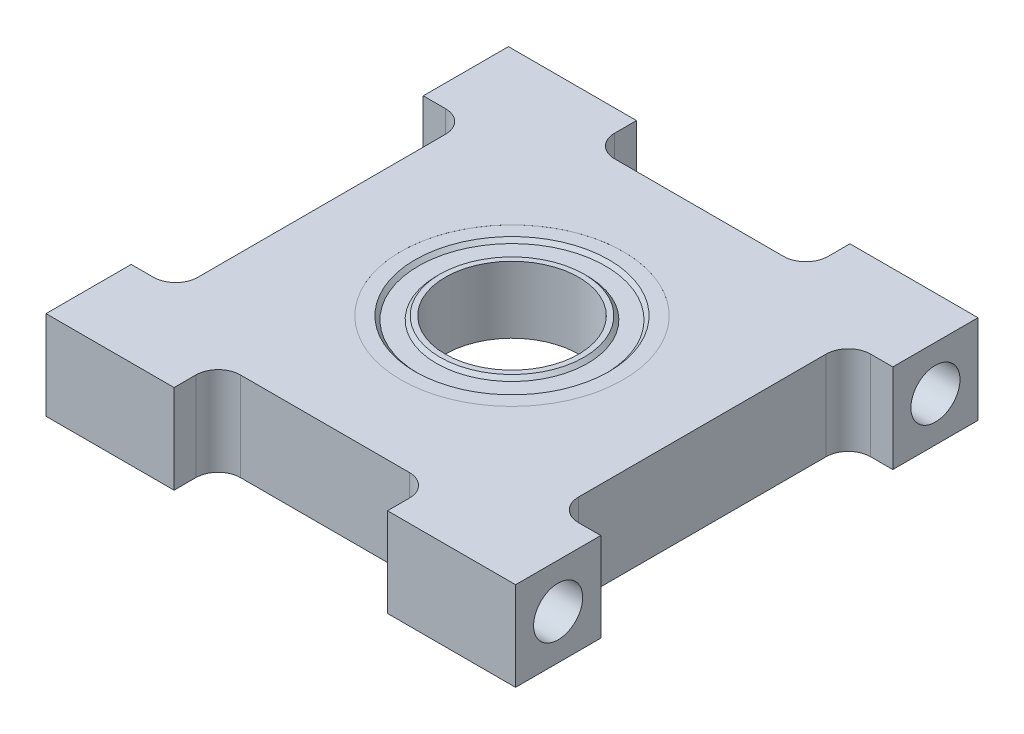
from build123d import *

# Parameters (mm, degrees)
SKETCH1_R                      = 7.62
BOSS_EXTRUDE1_DEPTH            = 6.35
SKETCH2_R                      = 7.9375
CUT_EXTRUDE1_DEPTH             = 4.7625
SKETCH3_R                      = 7.9375
SKETCH3_R_2                    = 6.6675
BOSS_EXTRUDE2_DEPTH            = 4.75996
CHAMFER1_SIZE                  = 0.254
SKETCH4_R                      = 5.3975
SKETCH4_R_2                    = 4.7625
BOSS_EXTRUDE3_DEPTH            = 4.75996
CHAMFER2_SIZE                  = 0.254
SKETCH5_R                      = 6.6675
SKETCH5_R_2                    = 5.3975
BOSS_EXTRUDE4_DEPTH            = 4.2545
F_6_32_TAPPED_HOLE1_AT_2_COUNT = 2
F_6_32_TAPPED_HOLE1_AT_2_PITCH = 26.940768363


with BuildPart() as part:
    # Sketch1 → Boss-Extrude1 (new body)
    with BuildSketch(Plane(origin=(0, 0, 0), x_dir=(1, 0, 0), z_dir=(0, 1, 0))):
        with BuildLine():
            Line((-16.764, -16.51), (-7.62, -16.51))
            Line((-7.62, -16.51), (-7.62, -14.9479))
            ThreePointArc((-7.62, -14.9479), (-7.155032015, -13.825367985), (-6.0325, -13.3604))
            Line((-6.0325, -13.3604), (6.0325, -13.3604))
            ThreePointArc((6.0325, -13.3604), (7.155032015, -13.825367985), (7.62, -14.9479))
            Line((7.62, -14.9479), (7.62, -16.51))
            Line((7.62, -16.51), (16.764, -16.51))
            Line((16.764, -16.51), (16.764, -10.4267))
            Line((16.764, -10.4267), (15.1765, -10.4267))
            ThreePointArc((15.1765, -10.4267), (14.053967985, -9.961732015), (13.589, -8.8392))
            Line((13.589, -8.8392), (13.589, 8.8392))
            ThreePointArc((13.589, 8.8392), (14.053967985, 9.961732015), (15.1765, 10.4267))
            Line((15.1765, 10.4267), (16.764, 10.4267))
            Line((16.764, 10.4267), (16.764, 16.51))
            Line((16.764, 16.51), (7.62, 16.51))
            Line((7.62, 16.51), (7.62, 14.9479))
            ThreePointArc((7.62, 14.9479), (7.155032015, 13.825367985), (6.0325, 13.3604))
            Line((6.0325, 13.3604), (-6.0325, 13.3604))
            ThreePointArc((-6.0325, 13.3604), (-7.155032015, 13.825367985), (-7.62, 14.9479))
            Line((-7.62, 14.9479), (-7.62, 16.51))
            Line((-7.62, 16.51), (-16.764, 16.51))
            Line((-16.764, 16.51), (-16.764, 10.4267))
            Line((-16.764, 10.4267), (-15.1765, 10.4267))
            ThreePointArc((-15.1765, 10.4267), (-14.053967985, 9.961732015), (-13.589, 8.8392))
            Line((-13.589, 8.8392), (-13.589, -8.8392))
            ThreePointArc((-13.589, -8.8392), (-14.053967985, -9.961732015), (-15.1765, -10.4267))
            Line((-15.1765, -10.4267), (-16.764, -10.4267))
            Line((-16.764, -10.4267), (-16.764, -16.51))
        make_face()
        Circle(SKETCH1_R, mode=Mode.SUBTRACT)
    extrude(amount=BOSS_EXTRUDE1_DEPTH)

    # Sketch2 → Cut-Extrude1 (cut)
    with BuildSketch(Plane(origin=(0, 6.35, 0), x_dir=(1, 0, 0), z_dir=(0, 1, 0))):
        Circle(SKETCH2_R)
    extrude(amount=-CUT_EXTRUDE1_DEPTH, mode=Mode.SUBTRACT)

    # Sketch3 → Boss-Extrude2 (add)
    with BuildSketch(Plane(origin=(0, 1.5875, 0), x_dir=(-1, 0, 0), z_dir=(0, 1, 0))):
        Circle(SKETCH3_R)
        Circle(SKETCH3_R_2, mode=Mode.SUBTRACT)
    extrude(amount=BOSS_EXTRUDE2_DEPTH)

    # Chamfer1
    chamfer1_edges = [part.edges().sort_by_distance(p)[0] for p in [
        (6.6675, 1.5875, 0),
        (6.6675, 6.34746, 0),
    ]]
    chamfer(chamfer1_edges, length=CHAMFER1_SIZE)



with BuildPart() as body_2:
    # Sketch4 → Boss-Extrude3 (new body)
    with BuildSketch(Plane(origin=(0, 1.5875, 0), x_dir=(-1, 0, 0), z_dir=(0, 1, 0))):
        Circle(SKETCH4_R)
        Circle(SKETCH4_R_2, mode=Mode.SUBTRACT)
    extrude(amount=BOSS_EXTRUDE3_DEPTH)

    # Chamfer2
    chamfer2_edges = [body_2.edges().sort_by_distance(p)[0] for p in [
        (5.3975, 1.5875, 0),
        (5.3975, 6.34746, 0),
    ]]
    chamfer(chamfer2_edges, length=CHAMFER2_SIZE)


with BuildPart() as part_1:
    add(part.part)

    add(body_2.part)  # Boss-Extrude4 merges body 2
    # Sketch5 → Boss-Extrude4 (add)
    with BuildSketch(Plane(origin=(0, 6.09346, 0), x_dir=(-1, 0, 0), z_dir=(0, 1, 0))):
        Circle(SKETCH5_R)
        Circle(SKETCH5_R_2, mode=Mode.SUBTRACT)
    extrude(amount=-BOSS_EXTRUDE4_DEPTH)

    # Sketch8 → #6-32 Tapped Hole1 (revolve, cut)
    with BuildSketch(Plane(origin=(-16.764, 3.175, -13.470384182), x_dir=(0, 0, 1), z_dir=(0, 1, 0))):
        Polygon((0, 0), (0, 8.76289403), (1.35255, 7.9502), (1.35255, 7.0104), (1.7526, 7.0104), (1.7526, 0), align=None)
    f_6_32_tapped_hole1 = revolve(axis=Axis((-23.114, 3.175, -13.470384182), (1, 0, 0)), mode=Mode.SUBTRACT)

    # #6-32 Tapped Hole1 at 2: #6-32 Tapped Hole1 ×2
    with Locations(*[(0, 0, i * F_6_32_TAPPED_HOLE1_AT_2_PITCH) for i in range(1, F_6_32_TAPPED_HOLE1_AT_2_COUNT)]):
        add(f_6_32_tapped_hole1, mode=Mode.SUBTRACT)

    # Mirror1: #6-32 Tapped Hole1 across plane
    add(f_6_32_tapped_hole1.mirror(Plane(origin=(0, 0, 0), x_dir=(0, 0, 1), z_dir=(1, 0, 0))), mode=Mode.SUBTRACT)

    # Mirror1 copy 1 sketch → Mirror1 copy 1 (revolve, cut)
    with BuildSketch(Plane(origin=(16.764, 3.175, 13.470384182), x_dir=(0, 0, 1), z_dir=(0, 1, 0))):
        Polygon((0, 0), (0, -8.76289403), (1.35255, -7.9502), (1.35255, -7.0104), (1.7526, -7.0104), (1.7526, 0), align=None)
    revolve(axis=Axis((23.114, 3.175, 13.470384182), (1, 0, 0)), mode=Mode.SUBTRACT)


solid = part_1.part
